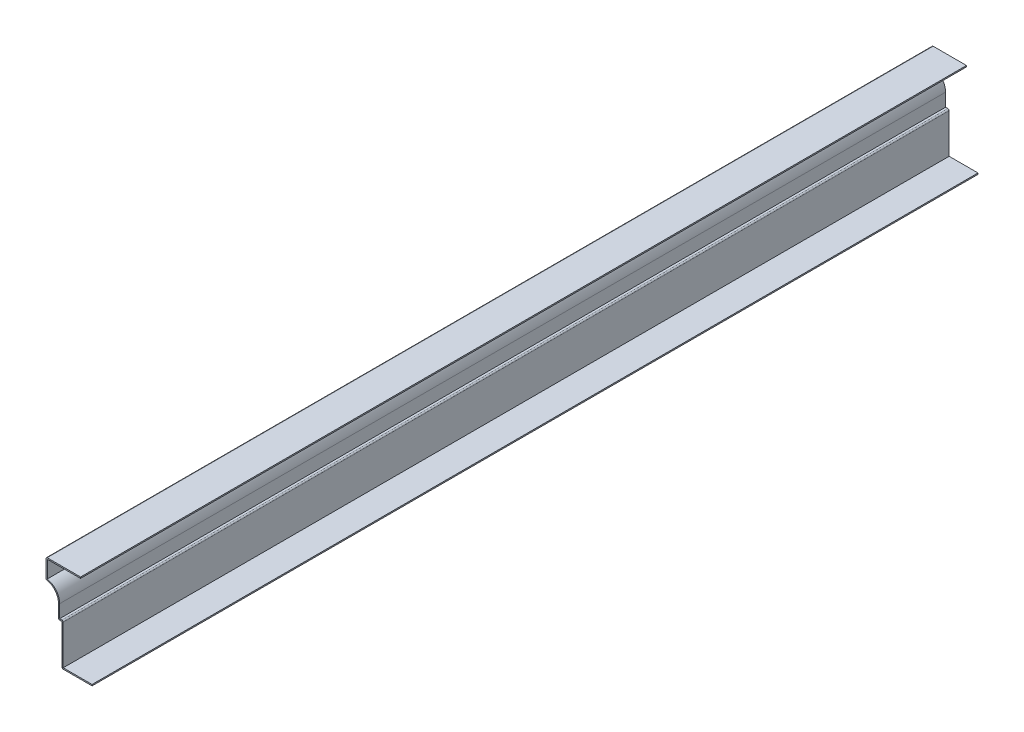
from build123d import *

# Parameters (mm, degrees)
EXTRUDE_THIN1_DEPTH = 793.75
FILLET1_R           = 1.143


with BuildPart() as part:
    # Sketch1 → Extrude-Thin1 (new body)
    with BuildSketch(Plane.XY):
        with BuildLine():
            Line((0, 0), (-26.9875, 0))
            Line((-26.9875, 0), (-26.9875, 36.5125))
            Line((-26.9875, 36.5125), (-30.1625, 36.5125))
            Line((-30.1625, 36.5125), (-30.1625, 49.312109381))
            ThreePointArc((-30.1625, 49.312109381), (-33.3375, 57.712369794), (-41.275, 61.9125))
            Line((-41.275, 61.9125), (-41.275, 79.375))
            Line((-41.275, 79.375), (-10.31875, 79.375))
            Line((-10.31875, 79.375), (-10.31875, 78.232))
            Line((-10.31875, 78.232), (-40.132, 78.232))
            Line((-40.132, 78.232), (-40.132, 62.883145405))
            ThreePointArc((-40.132, 62.883145405), (-32.152062089, 58.082238727), (-29.0195, 49.312109381))
            Line((-29.0195, 49.312109381), (-29.0195, 37.6555))
            Line((-29.0195, 37.6555), (-25.8445, 37.6555))
            Line((-25.8445, 37.6555), (-25.8445, 1.143))
            Line((-25.8445, 1.143), (0, 1.143))
            Line((0, 1.143), (0, 0))
        make_face()
    extrude(amount=-EXTRUDE_THIN1_DEPTH)

    # Fillet1
    fillet1_edges = [part.edges().sort_by_distance(p)[0] for p in [
        (-25.8445, 37.6555, -396.875),
        (-26.9875, 0, -396.875),
        (-30.1625, 36.5125, -396.875),
        (-41.275, 61.9125, -396.875),
        (-41.275, 79.375, -396.875),
    ]]
    fillet(fillet1_edges, radius=FILLET1_R)


solid = part.part
